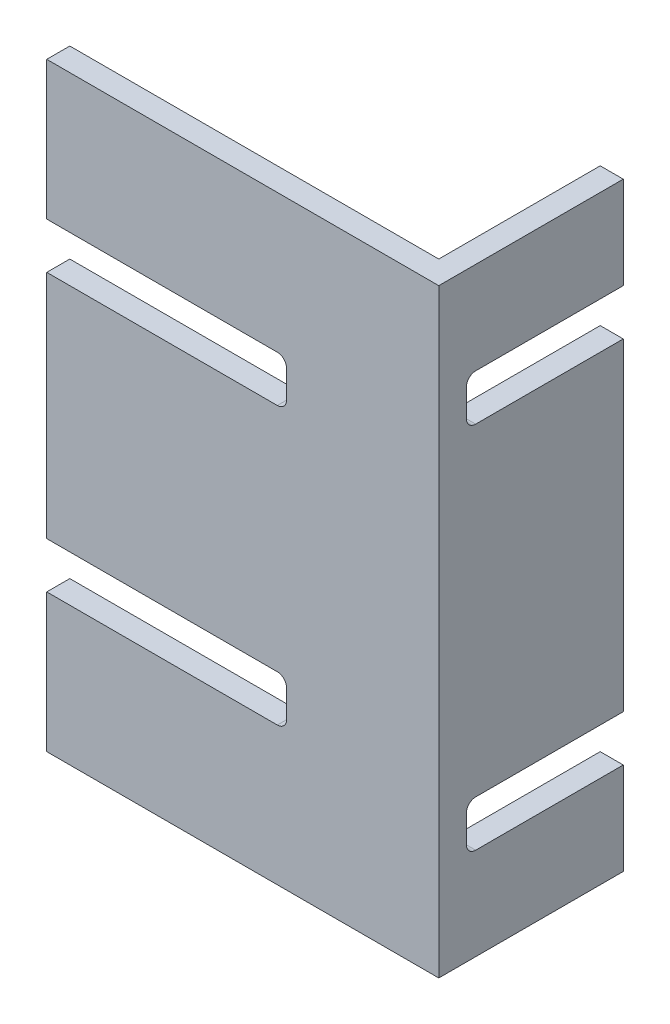
from build123d import *

# Parameters (mm, degrees)
BOSS_EXTRUDE1_DEPTH = 130
CUT_EXTRUDE1_DEPTH  = 10
CUT_EXTRUDE2_DEPTH  = 10


with BuildPart() as part:
    # Sketch1 → Boss-Extrude1 (new body)
    with BuildSketch(Plane(origin=(0, 0, 0), x_dir=(1, 0, 0), z_dir=(0, 1, 0))):
        Polygon((-95.340155061, -23.707512367), (-15.340155061, -23.707512367), (-15.340155061, 11.292487633), (-10.340155061, 11.292487633), (-10.340155061, -28.707512367), (-95.340155061, -28.707512367), align=None)
    extrude(amount=BOSS_EXTRUDE1_DEPTH)

    # Sketch2 → Cut-Extrude1 (cut)
    with BuildSketch(Plane.ZY.offset(15.340155061)):
        with BuildLine():
            Line((-11.292487633, 110), (20.707512367, 110))
            ThreePointArc((20.707512367, 110), (22.121725929, 109.414213562), (22.707512367, 108))
            Line((22.707512367, 108), (22.707512367, 102))
            ThreePointArc((22.707512367, 102), (22.121725929, 100.585786438), (20.707512367, 100))
            Line((20.707512367, 100), (-11.292487633, 100))
            Line((-11.292487633, 100), (-11.292487633, 110))
        make_face()
        with BuildLine():
            Line((-11.292487633, 30), (20.707512367, 30))
            ThreePointArc((20.707512367, 30), (22.121725929, 29.414213562), (22.707512367, 28))
            Line((22.707512367, 28), (22.707512367, 22))
            ThreePointArc((22.707512367, 22), (22.121725929, 20.585786438), (20.707512367, 20))
            Line((20.707512367, 20), (-11.292487633, 20))
            Line((-11.292487633, 20), (-11.292487633, 30))
        make_face()
    extrude(amount=-CUT_EXTRUDE1_DEPTH, mode=Mode.SUBTRACT)

    # Sketch3 → Cut-Extrude2 (cut)
    with BuildSketch(Plane(origin=(0, 0, 23.707512367), x_dir=(-1, 0, 0), z_dir=(0, 0, -1))):
        with BuildLine():
            Line((95.340155061, 100), (45.340155061, 100))
            ThreePointArc((45.340155061, 100), (43.925941499, 99.414213562), (43.340155061, 98))
            Line((43.340155061, 98), (43.340155061, 92))
            ThreePointArc((43.340155061, 92), (43.925941499, 90.585786438), (45.340155061, 90))
            Line((45.340155061, 90), (95.340155061, 90))
            Line((95.340155061, 90), (95.340155061, 100))
        make_face()
        with BuildLine():
            Line((95.340155061, 40), (45.340155061, 40))
            ThreePointArc((45.340155061, 40), (43.925941499, 39.414213562), (43.340155061, 38))
            Line((43.340155061, 38), (43.340155061, 32))
            ThreePointArc((43.340155061, 32), (43.925941499, 30.585786438), (45.340155061, 30))
            Line((45.340155061, 30), (95.340155061, 30))
            Line((95.340155061, 30), (95.340155061, 40))
        make_face()
    extrude(amount=-CUT_EXTRUDE2_DEPTH, mode=Mode.SUBTRACT)


solid = part.part
